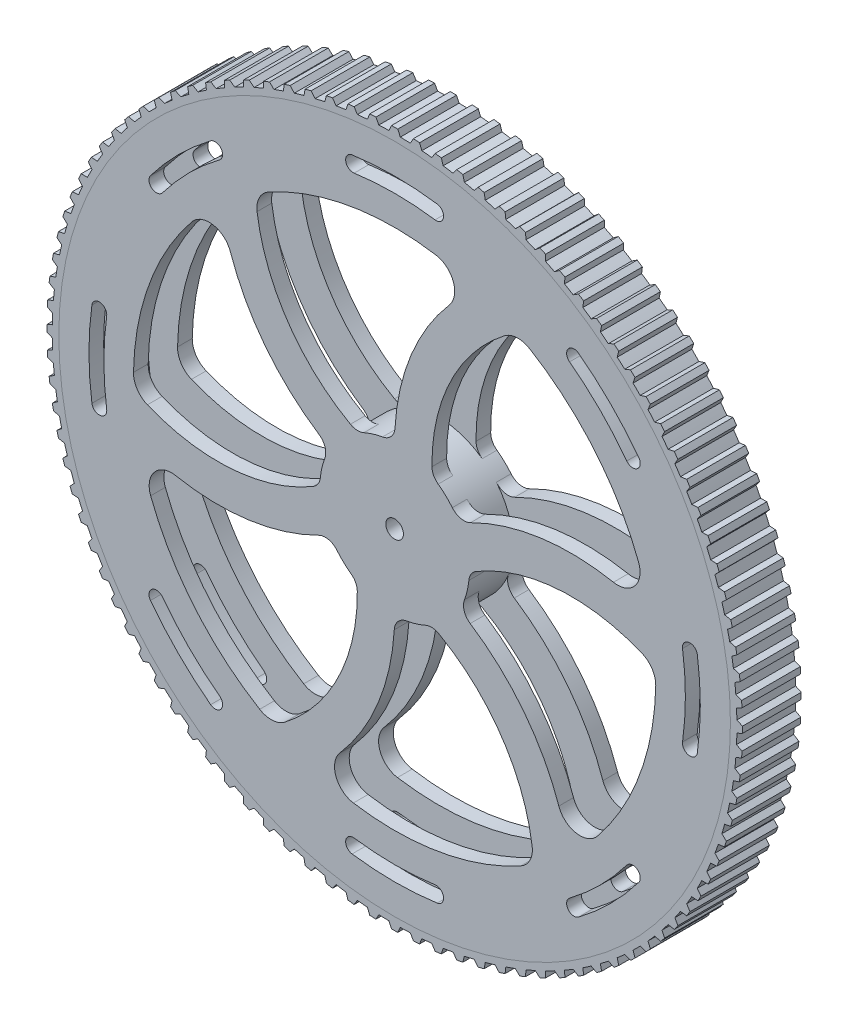
from build123d import *

# Parameters (mm, degrees)
SKETCH1_R           = 114.3
BOSS_EXTRUDE1_DEPTH = 10
CUT_EXTRUDE1_DEPTH  = 63.5
FILLET1_R           = 7.62
FILLET2_R           = 5.08
SKETCH4_R           = 3
CUT_EXTRUDE2_DEPTH  = 127
SKETCH5_R           = 114.3
BOSS_EXTRUDE2_DEPTH = 10
CUT_EXTRUDE5_DEPTH  = 21.0000001
SKETCH7_W           = 10
SKETCH7_H           = 88.9


with BuildPart() as part:
    # Sketch1 → Boss-Extrude1 (new body, symmetric)
    with BuildSketch(Plane.XY):
        Circle(SKETCH1_R)
    extrude(amount=BOSS_EXTRUDE1_DEPTH, both=True)

    # Sketch3 → Cut-Extrude1 (cut, symmetric)
    with BuildSketch(Plane.XY):
        with BuildLine():
            ThreePointArc((-21.997045256, 12.7), (-46.591798282, 35.380537262), (-59.100870723, 66.410067609))
            ThreePointArc((-59.100870723, 66.410067609), (-81.776817231, 34.867781168), (-88.837517383, -3.332492356))
            ThreePointArc((-88.837517383, -3.332492356), (-56.657320911, -10.11563277), (-25.399766495, 0.108912737))
            ThreePointArc((-25.399766495, 0.108912737), (-24.520365223, 6.62658957), (-21.997045256, 12.7))
        make_face()
        with BuildLine():
            ThreePointArc((0, 25.4), (7.344544927, 58.039949551), (27.962370255, 84.387889236))
            ThreePointArc((27.962370255, 84.387889236), (-10.69202435, 88.254691747), (-47.304781729, 75.269300685))
            ThreePointArc((-47.304781729, 75.269300685), (-37.089055409, 44.008862834), (-12.605562051, 22.051299403))
            ThreePointArc((-12.605562051, 22.051299403), (-6.521387703, 24.548553978), (0, 25.4))
        make_face()
        with BuildLine():
            ThreePointArc((21.997045256, 12.7), (53.936343209, 22.659412289), (87.063240978, 17.977821628))
            ThreePointArc((87.063240978, 17.977821628), (71.084792881, 53.386910579), (41.532735653, 78.60179304))
            ThreePointArc((41.532735653, 78.60179304), (19.568265502, 54.124495604), (12.794204444, 21.942386667))
            ThreePointArc((12.794204444, 21.942386667), (17.99897752, 17.921964408), (21.997045256, 12.7))
        make_face()
        with BuildLine():
            ThreePointArc((59.100870723, -66.410067609), (81.108807806, -36.394660273), (88.9, 0))
            ThreePointArc((88.9, 0), (88.884377973, 1.666539032), (88.837517383, 3.332492356))
            ThreePointArc((88.837517383, 3.332492356), (56.657320911, 10.11563277), (25.399766495, -0.108912737))
            ThreePointArc((25.399766495, -0.108912737), (24.520365223, -6.62658957), (21.997045256, -12.7))
            ThreePointArc((21.997045256, -12.7), (46.591798282, -35.380537262), (59.100870723, -66.410067609))
        make_face()
        with BuildLine():
            ThreePointArc((-27.962370255, -84.387889236), (10.69202435, -88.254691747), (47.304781729, -75.269300685))
            ThreePointArc((47.304781729, -75.269300685), (37.089055409, -44.008862834), (12.605562051, -22.051299403))
            ThreePointArc((12.605562051, -22.051299403), (6.521387703, -24.548553978), (0, -25.4))
            ThreePointArc((0, -25.4), (-7.344544927, -58.039949551), (-27.962370255, -84.387889236))
        make_face()
        with BuildLine():
            ThreePointArc((-87.063240978, -17.977821628), (-71.084792881, -53.386910579), (-41.532735653, -78.60179304))
            ThreePointArc((-41.532735653, -78.60179304), (-19.568265502, -54.124495604), (-12.794204444, -21.942386667))
            ThreePointArc((-12.794204444, -21.942386667), (-17.99897752, -17.921964408), (-21.997045256, -12.7))
            ThreePointArc((-21.997045256, -12.7), (-53.936343209, -22.659412289), (-87.063240978, -17.977821628))
        make_face()
    extrude(amount=CUT_EXTRUDE1_DEPTH, both=True, mode=Mode.SUBTRACT)

    # Fillet1
    fillet1_edges = [part.edges().sort_by_distance(p)[0] for p in [
        (-87.063240978, -17.977821628, 0),
        (-88.837517383, -3.332492356, 0),
        (-41.532735653, -78.60179304, 0),
        (-47.304781729, 75.269300685, 0),
        (27.962370255, 84.387889236, 0),
        (87.063240978, 17.977821628, 0),
        (41.532735653, 78.60179304, 0),
        (59.100870723, -66.410067609, 0),
        (88.837517383, 3.332492356, 0),
        (-27.962370255, -84.387889236, 0),
        (47.304781729, -75.269300685, 0),
        (-59.100870723, 66.410067609, 0),
    ]]
    fillet(fillet1_edges, radius=FILLET1_R)

    # Fillet2
    fillet2_edges = [part.edges().sort_by_distance(p)[0] for p in [
        (-21.997045256, 12.7, 0),
        (-25.399766495, 0.108912737, 0),
        (-21.997045256, -12.7, 0),
        (-12.794204444, -21.942386667, 0),
        (0, 25.4, 0),
        (-12.605562051, 22.051299403, 0),
        (21.997045256, 12.7, 0),
        (12.794204444, 21.942386667, 0),
        (21.997045256, -12.7, 0),
        (25.399766495, -0.108912737, 0),
        (0, -25.4, 0),
        (12.605562051, -22.051299403, 0),
    ]]
    fillet(fillet2_edges, radius=FILLET2_R)

    # Sketch4 → Cut-Extrude2 (cut)
    with BuildSketch(Plane.XY.offset(10)):
        Circle(SKETCH4_R)
    extrude(amount=-CUT_EXTRUDE2_DEPTH, mode=Mode.SUBTRACT)

    # Sketch6 → Cut-Extrude5 (cut, through all)
    with BuildSketch(Plane.XY.offset(10)):
        with BuildLine():
            ThreePointArc((14.480249762, 103.032330732), (0, 104.044888434), (-14.480249762, 103.032330732))
            ThreePointArc((-14.480249762, 103.032330732), (-16.642030981, 100.163550161), (-13.77325041, 98.001768943))
            ThreePointArc((-13.77325041, 98.001768943), (0, 98.964888434), (13.77325041, 98.001768943))
            ThreePointArc((13.77325041, 98.001768943), (16.642030981, 100.163550161), (14.480249762, 103.032330732))
        make_face()
        with BuildLine():
            ThreePointArc((83.093942542, 62.615776942), (73.570846159, 73.570846159), (62.615776942, 83.093942542))
            ThreePointArc((62.615776942, 83.093942542), (59.058632587, 82.594018505), (59.558556624, 79.036874151))
            ThreePointArc((59.558556624, 79.036874151), (69.978743711, 69.978743711), (79.036874151, 59.558556624))
            ThreePointArc((79.036874151, 59.558556624), (82.594018505, 59.058632587), (83.093942542, 62.615776942))
        make_face()
        with BuildLine():
            ThreePointArc((103.032330732, -14.480249762), (104.044888434, 0), (103.032330732, 14.480249762))
            ThreePointArc((103.032330732, 14.480249762), (100.163550161, 16.642030981), (98.001768943, 13.77325041))
            ThreePointArc((98.001768943, 13.77325041), (98.964888434, 0), (98.001768943, -13.77325041))
            ThreePointArc((98.001768943, -13.77325041), (100.163550161, -16.642030981), (103.032330732, -14.480249762))
        make_face()
        with BuildLine():
            ThreePointArc((62.615776942, -83.093942542), (73.570846159, -73.570846159), (83.093942542, -62.615776942))
            ThreePointArc((83.093942542, -62.615776942), (82.594018505, -59.058632587), (79.036874151, -59.558556624))
            ThreePointArc((79.036874151, -59.558556624), (69.978743711, -69.978743711), (59.558556624, -79.036874151))
            ThreePointArc((59.558556624, -79.036874151), (59.058632587, -82.594018505), (62.615776942, -83.093942542))
        make_face()
        with BuildLine():
            ThreePointArc((-14.480249762, -103.032330732), (0, -104.044888434), (14.480249762, -103.032330732))
            ThreePointArc((14.480249762, -103.032330732), (16.642030981, -100.163550161), (13.77325041, -98.001768943))
            ThreePointArc((13.77325041, -98.001768943), (0, -98.964888434), (-13.77325041, -98.001768943))
            ThreePointArc((-13.77325041, -98.001768943), (-16.642030981, -100.163550161), (-14.480249762, -103.032330732))
        make_face()
        with BuildLine():
            ThreePointArc((-83.093942542, -62.615776942), (-73.570846159, -73.570846159), (-62.615776942, -83.093942542))
            ThreePointArc((-62.615776942, -83.093942542), (-59.058632587, -82.594018505), (-59.558556624, -79.036874151))
            ThreePointArc((-59.558556624, -79.036874151), (-69.978743711, -69.978743711), (-79.036874151, -59.558556624))
            ThreePointArc((-79.036874151, -59.558556624), (-82.594018505, -59.058632587), (-83.093942542, -62.615776942))
        make_face()
        with BuildLine():
            ThreePointArc((-103.032330732, 14.480249762), (-104.044888434, 0), (-103.032330732, -14.480249762))
            ThreePointArc((-103.032330732, -14.480249762), (-100.163550161, -16.642030981), (-98.001768943, -13.77325041))
            ThreePointArc((-98.001768943, -13.77325041), (-98.964888434, 0), (-98.001768943, 13.77325041))
            ThreePointArc((-98.001768943, 13.77325041), (-100.163550161, 16.642030981), (-103.032330732, 14.480249762))
        make_face()
        with BuildLine():
            ThreePointArc((-62.615776942, 83.093942542), (-73.570846159, 73.570846159), (-83.093942542, 62.615776942))
            ThreePointArc((-83.093942542, 62.615776942), (-82.594018505, 59.058632587), (-79.036874151, 59.558556624))
            ThreePointArc((-79.036874151, 59.558556624), (-69.978743711, 69.978743711), (-59.558556624, 79.036874151))
            ThreePointArc((-59.558556624, 79.036874151), (-59.058632587, 82.594018505), (-62.615776942, 83.093942542))
        make_face()
    extrude(amount=-CUT_EXTRUDE5_DEPTH, mode=Mode.SUBTRACT)

    # Sketch7 → Cut-Revolve1 (revolve, cut)
    with BuildSketch(Plane(origin=(0, 0, 0), x_dir=(0, 0, -1), z_dir=(1, 0, 0))):
        with Locations((0, 69.85)):
            Rectangle(SKETCH7_W, SKETCH7_H)
    revolve(axis=Axis((0, 0, 0), (0, 0, -1)), mode=Mode.SUBTRACT)


with BuildPart() as body_2:
    # Sketch5 → Boss-Extrude2 (new body, symmetric)
    with BuildSketch(Plane.XY):
        with BuildLine():
            Line((-1.058611746, 118.395267393), (-1.95, 116.483679114))
            ThreePointArc((-1.95, 116.483679114), (-3.659353433, 116.442514283), (-5.367918608, 116.376266695))
            Line((-5.367918608, 116.376266695), (-6.377577532, 118.22811216))
            ThreePointArc((-6.377577532, 118.22811216), (-7.434397512, 118.166364646), (-8.490623167, 118.095170597))
            Line((-8.490623167, 118.095170597), (-9.260222849, 116.131383669))
            ThreePointArc((-9.260222849, 116.131383669), (-10.963618502, 115.982968876), (-12.664652493, 115.809570318))
            Line((-12.664652493, 115.809570318), (-13.788597425, 117.59436458))
            ThreePointArc((-13.788597425, 117.59436458), (-14.839454854, 117.466380636), (-15.889125978, 117.329006114))
            Line((-15.889125978, 117.329006114), (-16.533899828, 115.320770707))
            ThreePointArc((-16.533899828, 115.320770707), (-18.224615177, 115.065691679), (-19.911404781, 114.785826475))
            Line((-19.911404781, 114.785826475), (-21.145200023, 116.496525768))
            ThreePointArc((-21.145200023, 116.496525768), (-22.185947647, 116.302810486), (-23.224921667, 116.099797647))
            Line((-23.224921667, 116.099797647), (-23.742325059, 114.055039348))
            ThreePointArc((-23.742325059, 114.055039348), (-25.413687623, 113.694302766), (-27.079575851, 113.309075416))
            Line((-27.079575851, 113.309075416), (-28.418352177, 114.93892839))
            ThreePointArc((-28.418352177, 114.93892839), (-29.44488264, 114.680246278), (-30.4690592, 114.412396319))
            Line((-30.4690592, 114.412396319), (-30.85705018, 112.339184856))
            ThreePointArc((-30.85705018, 112.339184856), (-32.502463854, 111.874214381), (-34.140876207, 111.385145203))
            Line((-34.140876207, 111.385145203), (-35.579350079, 112.927719573))
            ThreePointArc((-35.579350079, 112.927719573), (-36.587612134, 112.605091529), (-37.592949278, 112.273461533))
            Line((-37.592949278, 112.273461533), (-37.84999662, 110.179978925))
            ThreePointArc((-37.84999662, 110.179978925), (-39.462967709, 109.612609583), (-41.067438122, 109.021628708))
            Line((-41.067438122, 109.021628708), (-42.59993254, 110.470836638))
            ThreePointArc((-42.59993254, 110.470836638), (-43.585947038, 110.085535929), (-44.568477158, 109.691434687))
            Line((-44.568477158, 109.691434687), (-44.693566416, 107.585942952))
            ThreePointArc((-44.693566416, 107.585942952), (-46.267729259, 106.918413892), (-47.83192562, 106.227853652))
            Line((-47.83192562, 106.227853652), (-49.452392529, 107.577975781))
            ThreePointArc((-49.452392529, 107.577975781), (-50.412268121, 107.131523012), (-51.368113621, 106.676505862))
            Line((-51.368113621, 106.676505862), (-51.360751124, 104.567314415))
            ThreePointArc((-51.360751124, 104.567314415), (-52.88989322, 103.802260068), (-54.40764236, 103.014845788))
            Line((-54.40764236, 103.014845788), (-56.109686518, 104.260553801))
            ThreePointArc((-56.109686518, 104.260553801), (-57.039635014, 103.754710917), (-57.965023608, 103.240573604))
            Line((-57.965023608, 103.240573604), (-57.825238412, 101.136006459))
            ThreePointArc((-57.825238412, 101.136006459), (-59.303324935, 100.276446146), (-60.768636992, 99.395285392))
            Line((-60.768636992, 99.395285392), (-62.545541209, 100.531663047))
            ThreePointArc((-62.545541209, 100.531663047), (-63.441892526, 99.968426379), (-64.333172128, 99.397197969))
            Line((-64.333172128, 99.397197969), (-64.061515902, 97.305560891))
            ThreePointArc((-64.061515902, 97.305560891), (-65.48271352, 96.354886903), (-66.889805577, 95.383457213))
            Line((-66.889805577, 95.383457213), (-68.734557222, 96.406019747))
            ThreePointArc((-68.734557222, 96.406019747), (-69.593773871, 95.787612134), (-70.447427008, 95.161547003))
            Line((-70.447427008, 95.161547003), (-70.044971855, 93.091094729))
            ThreePointArc((-70.044971855, 93.091094729), (-71.403671751, 92.053058942), (-72.746990658, 90.995194105))
            Line((-72.746990658, 90.995194105), (-74.65230934, 91.899905931))
            ThreePointArc((-74.65230934, 91.899905931), (-75.471000386, 91.228767945), (-76.283658079, 90.550336886))
            Line((-76.283658079, 90.550336886), (-75.751992305, 88.509240545))
            ThreePointArc((-75.751992305, 88.509240545), (-77.04283231, 87.387939612), (-78.317076602, 86.247814537))
            Line((-78.317076602, 86.247814537), (-80.275442898, 87.031105172))
            ThreePointArc((-80.275442898, 87.031105172), (-81.050377342, 86.309885487), (-81.818832401, 85.581765958))
            Line((-81.818832401, 85.581765958), (-81.160054249, 83.578080824))
            ThreePointArc((-81.160054249, 83.578080824), (-82.377940008, 82.377940008), (-83.578080824, 81.160054249))
            Line((-83.578080824, 81.160054249), (-85.581765958, 81.818832401))
            ThreePointArc((-85.581765958, 81.818832401), (-86.309885487, 81.050377342), (-87.031105172, 80.275442898))
            Line((-87.031105172, 80.275442898), (-86.247814537, 78.317076602))
            ThreePointArc((-86.247814537, 78.317076602), (-87.387939612, 77.04283231), (-88.509240545, 75.751992305))
            Line((-88.509240545, 75.751992305), (-90.550336886, 76.283658079))
            ThreePointArc((-90.550336886, 76.283658079), (-91.228767945, 75.471000386), (-91.899905931, 74.65230934))
            Line((-91.899905931, 74.65230934), (-90.995194105, 72.746990658))
            ThreePointArc((-90.995194105, 72.746990658), (-92.053058942, 71.403671751), (-93.091094729, 70.044971855))
            Line((-93.091094729, 70.044971855), (-95.161547003, 70.447427008))
            ThreePointArc((-95.161547003, 70.447427008), (-95.787612134, 69.593773871), (-96.406019747, 68.734557222))
            Line((-96.406019747, 68.734557222), (-95.383457213, 66.889805577))
            ThreePointArc((-95.383457213, 66.889805577), (-96.354886903, 65.48271352), (-97.305560891, 64.061515902))
            Line((-97.305560891, 64.061515902), (-99.397197969, 64.333172128))
            ThreePointArc((-99.397197969, 64.333172128), (-99.968426379, 63.441892526), (-100.531663047, 62.545541209))
            Line((-100.531663047, 62.545541209), (-99.395285392, 60.768636992))
            ThreePointArc((-99.395285392, 60.768636992), (-100.276446146, 59.303324935), (-101.136006459, 57.825238412))
            Line((-101.136006459, 57.825238412), (-103.240573604, 57.965023608))
            ThreePointArc((-103.240573604, 57.965023608), (-103.754710917, 57.039635014), (-104.260553801, 56.109686518))
            Line((-104.260553801, 56.109686518), (-103.014845788, 54.40764236))
            ThreePointArc((-103.014845788, 54.40764236), (-103.802260068, 52.88989322), (-104.567314415, 51.360751124))
            Line((-104.567314415, 51.360751124), (-106.676505862, 51.368113621))
            ThreePointArc((-106.676505862, 51.368113621), (-107.131523012, 50.412268121), (-107.577975781, 49.452392529))
            Line((-107.577975781, 49.452392529), (-106.227853652, 47.83192562))
            ThreePointArc((-106.227853652, 47.83192562), (-106.918413892, 46.267729259), (-107.585942952, 44.693566416))
            Line((-107.585942952, 44.693566416), (-109.691434687, 44.568477158))
            ThreePointArc((-109.691434687, 44.568477158), (-110.085535929, 43.585947038), (-110.470836638, 42.59993254))
            Line((-110.470836638, 42.59993254), (-109.021628708, 41.067438122))
            ThreePointArc((-109.021628708, 41.067438122), (-109.612609583, 39.462967709), (-110.179978925, 37.84999662))
            Line((-110.179978925, 37.84999662), (-112.273461533, 37.592949278))
            ThreePointArc((-112.273461533, 37.592949278), (-112.605091529, 36.587612134), (-112.927719573, 35.579350079))
            Line((-112.927719573, 35.579350079), (-111.385145203, 34.140876207))
            ThreePointArc((-111.385145203, 34.140876207), (-111.874214381, 32.502463854), (-112.339184856, 30.85705018))
            Line((-112.339184856, 30.85705018), (-114.412396319, 30.4690592))
            ThreePointArc((-114.412396319, 30.4690592), (-114.680246278, 29.44488264), (-114.93892839, 28.418352177))
            Line((-114.93892839, 28.418352177), (-113.309075416, 27.079575851))
            ThreePointArc((-113.309075416, 27.079575851), (-113.694302766, 25.413687623), (-114.055039348, 23.742325059))
            Line((-114.055039348, 23.742325059), (-116.099797647, 23.224921667))
            ThreePointArc((-116.099797647, 23.224921667), (-116.302810486, 22.185947647), (-116.496525768, 21.145200023))
            Line((-116.496525768, 21.145200023), (-114.785826475, 19.911404781))
            ThreePointArc((-114.785826475, 19.911404781), (-115.065691679, 18.224615177), (-115.320770707, 16.533899828))
            Line((-115.320770707, 16.533899828), (-117.329006114, 15.889125978))
            ThreePointArc((-117.329006114, 15.889125978), (-117.466380636, 14.839454854), (-117.59436458, 13.788597425))
            Line((-117.59436458, 13.788597425), (-115.809570318, 12.664652493))
            ThreePointArc((-115.809570318, 12.664652493), (-115.982968876, 10.963618502), (-116.131383669, 9.260222849))
            Line((-116.131383669, 9.260222849), (-118.095170597, 8.490623167))
            ThreePointArc((-118.095170597, 8.490623167), (-118.166364646, 7.434397512), (-118.22811216, 6.377577532))
            Line((-118.22811216, 6.377577532), (-116.376266695, 5.367918608))
            ThreePointArc((-116.376266695, 5.367918608), (-116.442514283, 3.659353433), (-116.483679114, 1.95))
            Line((-116.483679114, 1.95), (-118.395267393, 1.058611746))
            ThreePointArc((-118.395267393, 1.058611746), (-118.4, 0), (-118.395267393, -1.058611746))
            Line((-118.395267393, -1.058611746), (-116.483679114, -1.95))
            ThreePointArc((-116.483679114, -1.95), (-116.442514283, -3.659353433), (-116.376266695, -5.367918608))
            Line((-116.376266695, -5.367918608), (-118.22811216, -6.377577532))
            ThreePointArc((-118.22811216, -6.377577532), (-118.166364646, -7.434397512), (-118.095170597, -8.490623167))
            Line((-118.095170597, -8.490623167), (-116.131383669, -9.260222849))
            ThreePointArc((-116.131383669, -9.260222849), (-115.982968876, -10.963618502), (-115.809570318, -12.664652493))
            Line((-115.809570318, -12.664652493), (-117.59436458, -13.788597425))
            ThreePointArc((-117.59436458, -13.788597425), (-117.466380636, -14.839454854), (-117.329006114, -15.889125978))
            Line((-117.329006114, -15.889125978), (-115.320770707, -16.533899828))
            ThreePointArc((-115.320770707, -16.533899828), (-115.065691679, -18.224615177), (-114.785826475, -19.911404781))
            Line((-114.785826475, -19.911404781), (-116.496525768, -21.145200023))
            ThreePointArc((-116.496525768, -21.145200023), (-116.302810486, -22.185947647), (-116.099797647, -23.224921667))
            Line((-116.099797647, -23.224921667), (-114.055039348, -23.742325059))
            ThreePointArc((-114.055039348, -23.742325059), (-113.694302766, -25.413687623), (-113.309075416, -27.079575851))
            Line((-113.309075416, -27.079575851), (-114.93892839, -28.418352177))
            ThreePointArc((-114.93892839, -28.418352177), (-114.680246278, -29.44488264), (-114.412396319, -30.4690592))
            Line((-114.412396319, -30.4690592), (-112.339184856, -30.85705018))
            ThreePointArc((-112.339184856, -30.85705018), (-111.874214381, -32.502463854), (-111.385145203, -34.140876207))
            Line((-111.385145203, -34.140876207), (-112.927719573, -35.579350079))
            ThreePointArc((-112.927719573, -35.579350079), (-112.605091529, -36.587612134), (-112.273461533, -37.592949278))
            Line((-112.273461533, -37.592949278), (-110.179978925, -37.84999662))
            ThreePointArc((-110.179978925, -37.84999662), (-109.612609583, -39.462967709), (-109.021628708, -41.067438122))
            Line((-109.021628708, -41.067438122), (-110.470836638, -42.59993254))
            ThreePointArc((-110.470836638, -42.59993254), (-110.085535929, -43.585947038), (-109.691434687, -44.568477158))
            Line((-109.691434687, -44.568477158), (-107.585942952, -44.693566416))
            ThreePointArc((-107.585942952, -44.693566416), (-106.918413892, -46.267729259), (-106.227853652, -47.83192562))
            Line((-106.227853652, -47.83192562), (-107.577975781, -49.452392529))
            ThreePointArc((-107.577975781, -49.452392529), (-107.131523012, -50.412268121), (-106.676505862, -51.368113621))
            Line((-106.676505862, -51.368113621), (-104.567314415, -51.360751124))
            ThreePointArc((-104.567314415, -51.360751124), (-103.802260068, -52.88989322), (-103.014845788, -54.40764236))
            Line((-103.014845788, -54.40764236), (-104.260553801, -56.109686518))
            ThreePointArc((-104.260553801, -56.109686518), (-103.754710917, -57.039635014), (-103.240573604, -57.965023608))
            Line((-103.240573604, -57.965023608), (-101.136006459, -57.825238412))
            ThreePointArc((-101.136006459, -57.825238412), (-100.276446146, -59.303324935), (-99.395285392, -60.768636992))
            Line((-99.395285392, -60.768636992), (-100.531663047, -62.545541209))
            ThreePointArc((-100.531663047, -62.545541209), (-99.968426379, -63.441892526), (-99.397197969, -64.333172128))
            Line((-99.397197969, -64.333172128), (-97.305560891, -64.061515902))
            ThreePointArc((-97.305560891, -64.061515902), (-96.354886903, -65.48271352), (-95.383457213, -66.889805577))
            Line((-95.383457213, -66.889805577), (-96.406019747, -68.734557222))
            ThreePointArc((-96.406019747, -68.734557222), (-95.787612134, -69.593773871), (-95.161547003, -70.447427008))
            Line((-95.161547003, -70.447427008), (-93.091094729, -70.044971855))
            ThreePointArc((-93.091094729, -70.044971855), (-92.053058942, -71.403671751), (-90.995194105, -72.746990658))
            Line((-90.995194105, -72.746990658), (-91.899905931, -74.65230934))
            ThreePointArc((-91.899905931, -74.65230934), (-91.228767945, -75.471000386), (-90.550336886, -76.283658079))
            Line((-90.550336886, -76.283658079), (-88.509240545, -75.751992305))
            ThreePointArc((-88.509240545, -75.751992305), (-87.387939612, -77.04283231), (-86.247814537, -78.317076602))
            Line((-86.247814537, -78.317076602), (-87.031105172, -80.275442898))
            ThreePointArc((-87.031105172, -80.275442898), (-86.309885487, -81.050377342), (-85.581765958, -81.818832401))
            Line((-85.581765958, -81.818832401), (-83.578080824, -81.160054249))
            ThreePointArc((-83.578080824, -81.160054249), (-82.377940008, -82.377940008), (-81.160054249, -83.578080824))
            Line((-81.160054249, -83.578080824), (-81.818832401, -85.581765958))
            ThreePointArc((-81.818832401, -85.581765958), (-81.050377342, -86.309885487), (-80.275442898, -87.031105172))
            Line((-80.275442898, -87.031105172), (-78.317076602, -86.247814537))
            ThreePointArc((-78.317076602, -86.247814537), (-77.04283231, -87.387939612), (-75.751992305, -88.509240545))
            Line((-75.751992305, -88.509240545), (-76.283658079, -90.550336886))
            ThreePointArc((-76.283658079, -90.550336886), (-75.471000386, -91.228767945), (-74.65230934, -91.899905931))
            Line((-74.65230934, -91.899905931), (-72.746990658, -90.995194105))
            ThreePointArc((-72.746990658, -90.995194105), (-71.403671751, -92.053058942), (-70.044971855, -93.091094729))
            Line((-70.044971855, -93.091094729), (-70.447427008, -95.161547003))
            ThreePointArc((-70.447427008, -95.161547003), (-69.593773871, -95.787612134), (-68.734557222, -96.406019747))
            Line((-68.734557222, -96.406019747), (-66.889805577, -95.383457213))
            ThreePointArc((-66.889805577, -95.383457213), (-65.48271352, -96.354886903), (-64.061515902, -97.305560891))
            Line((-64.061515902, -97.305560891), (-64.333172128, -99.397197969))
            ThreePointArc((-64.333172128, -99.397197969), (-63.441892526, -99.968426379), (-62.545541209, -100.531663047))
            Line((-62.545541209, -100.531663047), (-60.768636992, -99.395285392))
            ThreePointArc((-60.768636992, -99.395285392), (-59.303324935, -100.276446146), (-57.825238412, -101.136006459))
            Line((-57.825238412, -101.136006459), (-57.965023608, -103.240573604))
            ThreePointArc((-57.965023608, -103.240573604), (-57.039635014, -103.754710917), (-56.109686518, -104.260553801))
            Line((-56.109686518, -104.260553801), (-54.40764236, -103.014845788))
            ThreePointArc((-54.40764236, -103.014845788), (-52.88989322, -103.802260068), (-51.360751124, -104.567314415))
            Line((-51.360751124, -104.567314415), (-51.368113621, -106.676505862))
            ThreePointArc((-51.368113621, -106.676505862), (-50.412268121, -107.131523012), (-49.452392529, -107.577975781))
            Line((-49.452392529, -107.577975781), (-47.83192562, -106.227853652))
            ThreePointArc((-47.83192562, -106.227853652), (-46.267729259, -106.918413892), (-44.693566416, -107.585942952))
            Line((-44.693566416, -107.585942952), (-44.568477158, -109.691434687))
            ThreePointArc((-44.568477158, -109.691434687), (-43.585947038, -110.085535929), (-42.59993254, -110.470836638))
            Line((-42.59993254, -110.470836638), (-41.067438122, -109.021628708))
            ThreePointArc((-41.067438122, -109.021628708), (-39.462967709, -109.612609583), (-37.84999662, -110.179978925))
            Line((-37.84999662, -110.179978925), (-37.592949278, -112.273461533))
            ThreePointArc((-37.592949278, -112.273461533), (-36.587612134, -112.605091529), (-35.579350079, -112.927719573))
            Line((-35.579350079, -112.927719573), (-34.140876207, -111.385145203))
            ThreePointArc((-34.140876207, -111.385145203), (-32.502463854, -111.874214381), (-30.85705018, -112.339184856))
            Line((-30.85705018, -112.339184856), (-30.4690592, -114.412396319))
            ThreePointArc((-30.4690592, -114.412396319), (-29.44488264, -114.680246278), (-28.418352177, -114.93892839))
            Line((-28.418352177, -114.93892839), (-27.079575851, -113.309075416))
            ThreePointArc((-27.079575851, -113.309075416), (-25.413687623, -113.694302766), (-23.742325059, -114.055039348))
            Line((-23.742325059, -114.055039348), (-23.224921667, -116.099797647))
            ThreePointArc((-23.224921667, -116.099797647), (-22.185947647, -116.302810486), (-21.145200023, -116.496525768))
            Line((-21.145200023, -116.496525768), (-19.911404781, -114.785826475))
            ThreePointArc((-19.911404781, -114.785826475), (-18.224615177, -115.065691679), (-16.533899828, -115.320770707))
            Line((-16.533899828, -115.320770707), (-15.889125978, -117.329006114))
            ThreePointArc((-15.889125978, -117.329006114), (-14.839454854, -117.466380636), (-13.788597425, -117.59436458))
            Line((-13.788597425, -117.59436458), (-12.664652493, -115.809570318))
            ThreePointArc((-12.664652493, -115.809570318), (-10.963618502, -115.982968876), (-9.260222849, -116.131383669))
            Line((-9.260222849, -116.131383669), (-8.490623167, -118.095170597))
            ThreePointArc((-8.490623167, -118.095170597), (-7.434397512, -118.166364646), (-6.377577532, -118.22811216))
            Line((-6.377577532, -118.22811216), (-5.367918608, -116.376266695))
            ThreePointArc((-5.367918608, -116.376266695), (-3.659353433, -116.442514283), (-1.95, -116.483679114))
            Line((-1.95, -116.483679114), (-1.058611746, -118.395267393))
            ThreePointArc((-1.058611746, -118.395267393), (0, -118.4), (1.058611746, -118.395267393))
            Line((1.058611746, -118.395267393), (1.95, -116.483679114))
            ThreePointArc((1.95, -116.483679114), (3.659353433, -116.442514283), (5.367918608, -116.376266695))
            Line((5.367918608, -116.376266695), (6.377577532, -118.22811216))
            ThreePointArc((6.377577532, -118.22811216), (7.434397512, -118.166364646), (8.490623167, -118.095170597))
            Line((8.490623167, -118.095170597), (9.260222849, -116.131383669))
            ThreePointArc((9.260222849, -116.131383669), (10.963618502, -115.982968876), (12.664652493, -115.809570318))
            Line((12.664652493, -115.809570318), (13.788597425, -117.59436458))
            ThreePointArc((13.788597425, -117.59436458), (14.839454854, -117.466380636), (15.889125978, -117.329006114))
            Line((15.889125978, -117.329006114), (16.533899828, -115.320770707))
            ThreePointArc((16.533899828, -115.320770707), (18.224615177, -115.065691679), (19.911404781, -114.785826475))
            Line((19.911404781, -114.785826475), (21.145200023, -116.496525768))
            ThreePointArc((21.145200023, -116.496525768), (22.185947647, -116.302810486), (23.224921667, -116.099797647))
            Line((23.224921667, -116.099797647), (23.742325059, -114.055039348))
            ThreePointArc((23.742325059, -114.055039348), (25.413687623, -113.694302766), (27.079575851, -113.309075416))
            Line((27.079575851, -113.309075416), (28.418352177, -114.93892839))
            ThreePointArc((28.418352177, -114.93892839), (29.44488264, -114.680246278), (30.4690592, -114.412396319))
            Line((30.4690592, -114.412396319), (30.85705018, -112.339184856))
            ThreePointArc((30.85705018, -112.339184856), (32.502463854, -111.874214381), (34.140876207, -111.385145203))
            Line((34.140876207, -111.385145203), (35.579350079, -112.927719573))
            ThreePointArc((35.579350079, -112.927719573), (36.587612134, -112.605091529), (37.592949278, -112.273461533))
            Line((37.592949278, -112.273461533), (37.84999662, -110.179978925))
            ThreePointArc((37.84999662, -110.179978925), (39.462967709, -109.612609583), (41.067438122, -109.021628708))
            Line((41.067438122, -109.021628708), (42.59993254, -110.470836638))
            ThreePointArc((42.59993254, -110.470836638), (43.585947038, -110.085535929), (44.568477158, -109.691434687))
            Line((44.568477158, -109.691434687), (44.693566416, -107.585942952))
            ThreePointArc((44.693566416, -107.585942952), (46.267729259, -106.918413892), (47.83192562, -106.227853652))
            Line((47.83192562, -106.227853652), (49.452392529, -107.577975781))
            ThreePointArc((49.452392529, -107.577975781), (50.412268121, -107.131523012), (51.368113621, -106.676505862))
            Line((51.368113621, -106.676505862), (51.360751124, -104.567314415))
            ThreePointArc((51.360751124, -104.567314415), (52.88989322, -103.802260068), (54.40764236, -103.014845788))
            Line((54.40764236, -103.014845788), (56.109686518, -104.260553801))
            ThreePointArc((56.109686518, -104.260553801), (57.039635014, -103.754710917), (57.965023608, -103.240573604))
            Line((57.965023608, -103.240573604), (57.825238412, -101.136006459))
            ThreePointArc((57.825238412, -101.136006459), (59.303324935, -100.276446146), (60.768636992, -99.395285392))
            Line((60.768636992, -99.395285392), (62.545541209, -100.531663047))
            ThreePointArc((62.545541209, -100.531663047), (63.441892526, -99.968426379), (64.333172128, -99.397197969))
            Line((64.333172128, -99.397197969), (64.061515902, -97.305560891))
            ThreePointArc((64.061515902, -97.305560891), (65.48271352, -96.354886903), (66.889805577, -95.383457213))
            Line((66.889805577, -95.383457213), (68.734557222, -96.406019747))
            ThreePointArc((68.734557222, -96.406019747), (69.593773871, -95.787612134), (70.447427008, -95.161547003))
            Line((70.447427008, -95.161547003), (70.044971855, -93.091094729))
            ThreePointArc((70.044971855, -93.091094729), (71.403671751, -92.053058942), (72.746990658, -90.995194105))
            Line((72.746990658, -90.995194105), (74.65230934, -91.899905931))
            ThreePointArc((74.65230934, -91.899905931), (75.471000386, -91.228767945), (76.283658079, -90.550336886))
            Line((76.283658079, -90.550336886), (75.751992305, -88.509240545))
            ThreePointArc((75.751992305, -88.509240545), (77.04283231, -87.387939612), (78.317076602, -86.247814537))
            Line((78.317076602, -86.247814537), (80.275442898, -87.031105172))
            ThreePointArc((80.275442898, -87.031105172), (81.050377342, -86.309885487), (81.818832401, -85.581765958))
            Line((81.818832401, -85.581765958), (81.160054249, -83.578080824))
            ThreePointArc((81.160054249, -83.578080824), (82.377940008, -82.377940008), (83.578080824, -81.160054249))
            Line((83.578080824, -81.160054249), (85.581765958, -81.818832401))
            ThreePointArc((85.581765958, -81.818832401), (86.309885487, -81.050377342), (87.031105172, -80.275442898))
            Line((87.031105172, -80.275442898), (86.247814537, -78.317076602))
            ThreePointArc((86.247814537, -78.317076602), (87.387939612, -77.04283231), (88.509240545, -75.751992305))
            Line((88.509240545, -75.751992305), (90.550336886, -76.283658079))
            ThreePointArc((90.550336886, -76.283658079), (91.228767945, -75.471000386), (91.899905931, -74.65230934))
            Line((91.899905931, -74.65230934), (90.995194105, -72.746990658))
            ThreePointArc((90.995194105, -72.746990658), (92.053058942, -71.403671751), (93.091094729, -70.044971855))
            Line((93.091094729, -70.044971855), (95.161547003, -70.447427008))
            ThreePointArc((95.161547003, -70.447427008), (95.787612134, -69.593773871), (96.406019747, -68.734557222))
            Line((96.406019747, -68.734557222), (95.383457213, -66.889805577))
            ThreePointArc((95.383457213, -66.889805577), (96.354886903, -65.48271352), (97.305560891, -64.061515902))
            Line((97.305560891, -64.061515902), (99.397197969, -64.333172128))
            ThreePointArc((99.397197969, -64.333172128), (99.968426379, -63.441892526), (100.531663047, -62.545541209))
            Line((100.531663047, -62.545541209), (99.395285392, -60.768636992))
            ThreePointArc((99.395285392, -60.768636992), (100.276446146, -59.303324935), (101.136006459, -57.825238412))
            Line((101.136006459, -57.825238412), (103.240573604, -57.965023608))
            ThreePointArc((103.240573604, -57.965023608), (103.754710917, -57.039635014), (104.260553801, -56.109686518))
            Line((104.260553801, -56.109686518), (103.014845788, -54.40764236))
            ThreePointArc((103.014845788, -54.40764236), (103.802260068, -52.88989322), (104.567314415, -51.360751124))
            Line((104.567314415, -51.360751124), (106.676505862, -51.368113621))
            ThreePointArc((106.676505862, -51.368113621), (107.131523012, -50.412268121), (107.577975781, -49.452392529))
            Line((107.577975781, -49.452392529), (106.227853652, -47.83192562))
            ThreePointArc((106.227853652, -47.83192562), (106.918413892, -46.267729259), (107.585942952, -44.693566416))
            Line((107.585942952, -44.693566416), (109.691434687, -44.568477158))
            ThreePointArc((109.691434687, -44.568477158), (110.085535929, -43.585947038), (110.470836638, -42.59993254))
            Line((110.470836638, -42.59993254), (109.021628708, -41.067438122))
            ThreePointArc((109.021628708, -41.067438122), (109.612609583, -39.462967709), (110.179978925, -37.84999662))
            Line((110.179978925, -37.84999662), (112.273461533, -37.592949278))
            ThreePointArc((112.273461533, -37.592949278), (112.605091529, -36.587612134), (112.927719573, -35.579350079))
            Line((112.927719573, -35.579350079), (111.385145203, -34.140876207))
            ThreePointArc((111.385145203, -34.140876207), (111.874214381, -32.502463854), (112.339184856, -30.85705018))
            Line((112.339184856, -30.85705018), (114.412396319, -30.4690592))
            ThreePointArc((114.412396319, -30.4690592), (114.680246278, -29.44488264), (114.93892839, -28.418352177))
            Line((114.93892839, -28.418352177), (113.309075416, -27.079575851))
            ThreePointArc((113.309075416, -27.079575851), (113.694302766, -25.413687623), (114.055039348, -23.742325059))
            Line((114.055039348, -23.742325059), (116.099797647, -23.224921667))
            ThreePointArc((116.099797647, -23.224921667), (116.302810486, -22.185947647), (116.496525768, -21.145200023))
            Line((116.496525768, -21.145200023), (114.785826475, -19.911404781))
            ThreePointArc((114.785826475, -19.911404781), (115.065691679, -18.224615177), (115.320770707, -16.533899828))
            Line((115.320770707, -16.533899828), (117.329006114, -15.889125978))
            ThreePointArc((117.329006114, -15.889125978), (117.466380636, -14.839454854), (117.59436458, -13.788597425))
            Line((117.59436458, -13.788597425), (115.809570318, -12.664652493))
            ThreePointArc((115.809570318, -12.664652493), (115.982968876, -10.963618502), (116.131383669, -9.260222849))
            Line((116.131383669, -9.260222849), (118.095170597, -8.490623167))
            ThreePointArc((118.095170597, -8.490623167), (118.166364646, -7.434397512), (118.22811216, -6.377577532))
            Line((118.22811216, -6.377577532), (116.376266695, -5.367918608))
            ThreePointArc((116.376266695, -5.367918608), (116.442514283, -3.659353433), (116.483679114, -1.95))
            Line((116.483679114, -1.95), (118.395267393, -1.058611746))
            ThreePointArc((118.395267393, -1.058611746), (118.4, 0), (118.395267393, 1.058611746))
            Line((118.395267393, 1.058611746), (116.483679114, 1.95))
            ThreePointArc((116.483679114, 1.95), (116.442514283, 3.659353433), (116.376266695, 5.367918608))
            Line((116.376266695, 5.367918608), (118.22811216, 6.377577532))
            ThreePointArc((118.22811216, 6.377577532), (118.166364646, 7.434397512), (118.095170597, 8.490623167))
            Line((118.095170597, 8.490623167), (116.131383669, 9.260222849))
            ThreePointArc((116.131383669, 9.260222849), (115.982968876, 10.963618502), (115.809570318, 12.664652493))
            Line((115.809570318, 12.664652493), (117.59436458, 13.788597425))
            ThreePointArc((117.59436458, 13.788597425), (117.466380636, 14.839454854), (117.329006114, 15.889125978))
            Line((117.329006114, 15.889125978), (115.320770707, 16.533899828))
            ThreePointArc((115.320770707, 16.533899828), (115.065691679, 18.224615177), (114.785826475, 19.911404781))
            Line((114.785826475, 19.911404781), (116.496525768, 21.145200023))
            ThreePointArc((116.496525768, 21.145200023), (116.302810486, 22.185947647), (116.099797647, 23.224921667))
            Line((116.099797647, 23.224921667), (114.055039348, 23.742325059))
            ThreePointArc((114.055039348, 23.742325059), (113.694302766, 25.413687623), (113.309075416, 27.079575851))
            Line((113.309075416, 27.079575851), (114.93892839, 28.418352177))
            ThreePointArc((114.93892839, 28.418352177), (114.680246278, 29.44488264), (114.412396319, 30.4690592))
            Line((114.412396319, 30.4690592), (112.339184856, 30.85705018))
            ThreePointArc((112.339184856, 30.85705018), (111.874214381, 32.502463854), (111.385145203, 34.140876207))
            Line((111.385145203, 34.140876207), (112.927719573, 35.579350079))
            ThreePointArc((112.927719573, 35.579350079), (112.605091529, 36.587612134), (112.273461533, 37.592949278))
            Line((112.273461533, 37.592949278), (110.179978925, 37.84999662))
            ThreePointArc((110.179978925, 37.84999662), (109.612609583, 39.462967709), (109.021628708, 41.067438122))
            Line((109.021628708, 41.067438122), (110.470836638, 42.59993254))
            ThreePointArc((110.470836638, 42.59993254), (110.085535929, 43.585947038), (109.691434687, 44.568477158))
            Line((109.691434687, 44.568477158), (107.585942952, 44.693566416))
            ThreePointArc((107.585942952, 44.693566416), (106.918413892, 46.267729259), (106.227853652, 47.83192562))
            Line((106.227853652, 47.83192562), (107.577975781, 49.452392529))
            ThreePointArc((107.577975781, 49.452392529), (107.131523012, 50.412268121), (106.676505862, 51.368113621))
            Line((106.676505862, 51.368113621), (104.567314415, 51.360751124))
            ThreePointArc((104.567314415, 51.360751124), (103.802260068, 52.88989322), (103.014845788, 54.40764236))
            Line((103.014845788, 54.40764236), (104.260553801, 56.109686518))
            ThreePointArc((104.260553801, 56.109686518), (103.754710917, 57.039635014), (103.240573604, 57.965023608))
            Line((103.240573604, 57.965023608), (101.136006459, 57.825238412))
            ThreePointArc((101.136006459, 57.825238412), (100.276446146, 59.303324935), (99.395285392, 60.768636992))
            Line((99.395285392, 60.768636992), (100.531663047, 62.545541209))
            ThreePointArc((100.531663047, 62.545541209), (99.968426379, 63.441892526), (99.397197969, 64.333172128))
            Line((99.397197969, 64.333172128), (97.305560891, 64.061515902))
            ThreePointArc((97.305560891, 64.061515902), (96.354886903, 65.48271352), (95.383457213, 66.889805577))
            Line((95.383457213, 66.889805577), (96.406019747, 68.734557222))
            ThreePointArc((96.406019747, 68.734557222), (95.787612134, 69.593773871), (95.161547003, 70.447427008))
            Line((95.161547003, 70.447427008), (93.091094729, 70.044971855))
            ThreePointArc((93.091094729, 70.044971855), (92.053058942, 71.403671751), (90.995194105, 72.746990658))
            Line((90.995194105, 72.746990658), (91.899905931, 74.65230934))
            ThreePointArc((91.899905931, 74.65230934), (91.228767945, 75.471000386), (90.550336886, 76.283658079))
            Line((90.550336886, 76.283658079), (88.509240545, 75.751992305))
            ThreePointArc((88.509240545, 75.751992305), (87.387939612, 77.04283231), (86.247814537, 78.317076602))
            Line((86.247814537, 78.317076602), (87.031105172, 80.275442898))
            ThreePointArc((87.031105172, 80.275442898), (86.309885487, 81.050377342), (85.581765958, 81.818832401))
            Line((85.581765958, 81.818832401), (83.578080824, 81.160054249))
            ThreePointArc((83.578080824, 81.160054249), (82.377940008, 82.377940008), (81.160054249, 83.578080824))
            Line((81.160054249, 83.578080824), (81.818832401, 85.581765958))
            ThreePointArc((81.818832401, 85.581765958), (81.050377342, 86.309885487), (80.275442898, 87.031105172))
            Line((80.275442898, 87.031105172), (78.317076602, 86.247814537))
            ThreePointArc((78.317076602, 86.247814537), (77.04283231, 87.387939612), (75.751992305, 88.509240545))
            Line((75.751992305, 88.509240545), (76.283658079, 90.550336886))
            ThreePointArc((76.283658079, 90.550336886), (75.471000386, 91.228767945), (74.65230934, 91.899905931))
            Line((74.65230934, 91.899905931), (72.746990658, 90.995194105))
            ThreePointArc((72.746990658, 90.995194105), (71.403671751, 92.053058942), (70.044971855, 93.091094729))
            Line((70.044971855, 93.091094729), (70.447427008, 95.161547003))
            ThreePointArc((70.447427008, 95.161547003), (69.593773871, 95.787612134), (68.734557222, 96.406019747))
            Line((68.734557222, 96.406019747), (66.889805577, 95.383457213))
            ThreePointArc((66.889805577, 95.383457213), (65.48271352, 96.354886903), (64.061515902, 97.305560891))
            Line((64.061515902, 97.305560891), (64.333172128, 99.397197969))
            ThreePointArc((64.333172128, 99.397197969), (63.441892526, 99.968426379), (62.545541209, 100.531663047))
            Line((62.545541209, 100.531663047), (60.768636992, 99.395285392))
            ThreePointArc((60.768636992, 99.395285392), (59.303324935, 100.276446146), (57.825238412, 101.136006459))
            Line((57.825238412, 101.136006459), (57.965023608, 103.240573604))
            ThreePointArc((57.965023608, 103.240573604), (57.039635014, 103.754710917), (56.109686518, 104.260553801))
            Line((56.109686518, 104.260553801), (54.40764236, 103.014845788))
            ThreePointArc((54.40764236, 103.014845788), (52.88989322, 103.802260068), (51.360751124, 104.567314415))
            Line((51.360751124, 104.567314415), (51.368113621, 106.676505862))
            ThreePointArc((51.368113621, 106.676505862), (50.412268121, 107.131523012), (49.452392529, 107.577975781))
            Line((49.452392529, 107.577975781), (47.83192562, 106.227853652))
            ThreePointArc((47.83192562, 106.227853652), (46.267729259, 106.918413892), (44.693566416, 107.585942952))
            Line((44.693566416, 107.585942952), (44.568477158, 109.691434687))
            ThreePointArc((44.568477158, 109.691434687), (43.585947038, 110.085535929), (42.59993254, 110.470836638))
            Line((42.59993254, 110.470836638), (41.067438122, 109.021628708))
            ThreePointArc((41.067438122, 109.021628708), (39.462967709, 109.612609583), (37.84999662, 110.179978925))
            Line((37.84999662, 110.179978925), (37.592949278, 112.273461533))
            ThreePointArc((37.592949278, 112.273461533), (36.587612134, 112.605091529), (35.579350079, 112.927719573))
            Line((35.579350079, 112.927719573), (34.140876207, 111.385145203))
            ThreePointArc((34.140876207, 111.385145203), (32.502463854, 111.874214381), (30.85705018, 112.339184856))
            Line((30.85705018, 112.339184856), (30.4690592, 114.412396319))
            ThreePointArc((30.4690592, 114.412396319), (29.44488264, 114.680246278), (28.418352177, 114.93892839))
            Line((28.418352177, 114.93892839), (27.079575851, 113.309075416))
            ThreePointArc((27.079575851, 113.309075416), (25.413687623, 113.694302766), (23.742325059, 114.055039348))
            Line((23.742325059, 114.055039348), (23.224921667, 116.099797647))
            ThreePointArc((23.224921667, 116.099797647), (22.185947647, 116.302810486), (21.145200023, 116.496525768))
            Line((21.145200023, 116.496525768), (19.911404781, 114.785826475))
            ThreePointArc((19.911404781, 114.785826475), (18.224615177, 115.065691679), (16.533899828, 115.320770707))
            Line((16.533899828, 115.320770707), (15.889125978, 117.329006114))
            ThreePointArc((15.889125978, 117.329006114), (14.839454854, 117.466380636), (13.788597425, 117.59436458))
            Line((13.788597425, 117.59436458), (12.664652493, 115.809570318))
            ThreePointArc((12.664652493, 115.809570318), (10.963618502, 115.982968876), (9.260222849, 116.131383669))
            Line((9.260222849, 116.131383669), (8.490623167, 118.095170597))
            ThreePointArc((8.490623167, 118.095170597), (7.434397512, 118.166364646), (6.377577532, 118.22811216))
            Line((6.377577532, 118.22811216), (5.367918608, 116.376266695))
            ThreePointArc((5.367918608, 116.376266695), (3.659353433, 116.442514283), (1.95, 116.483679114))
            Line((1.95, 116.483679114), (1.058611746, 118.395267393))
            ThreePointArc((1.058611746, 118.395267393), (0, 118.4), (-1.058611746, 118.395267393))
        make_face()
        Circle(SKETCH5_R, mode=Mode.SUBTRACT)
    extrude(amount=BOSS_EXTRUDE2_DEPTH, both=True)


solid = Compound([part.part, body_2.part])
